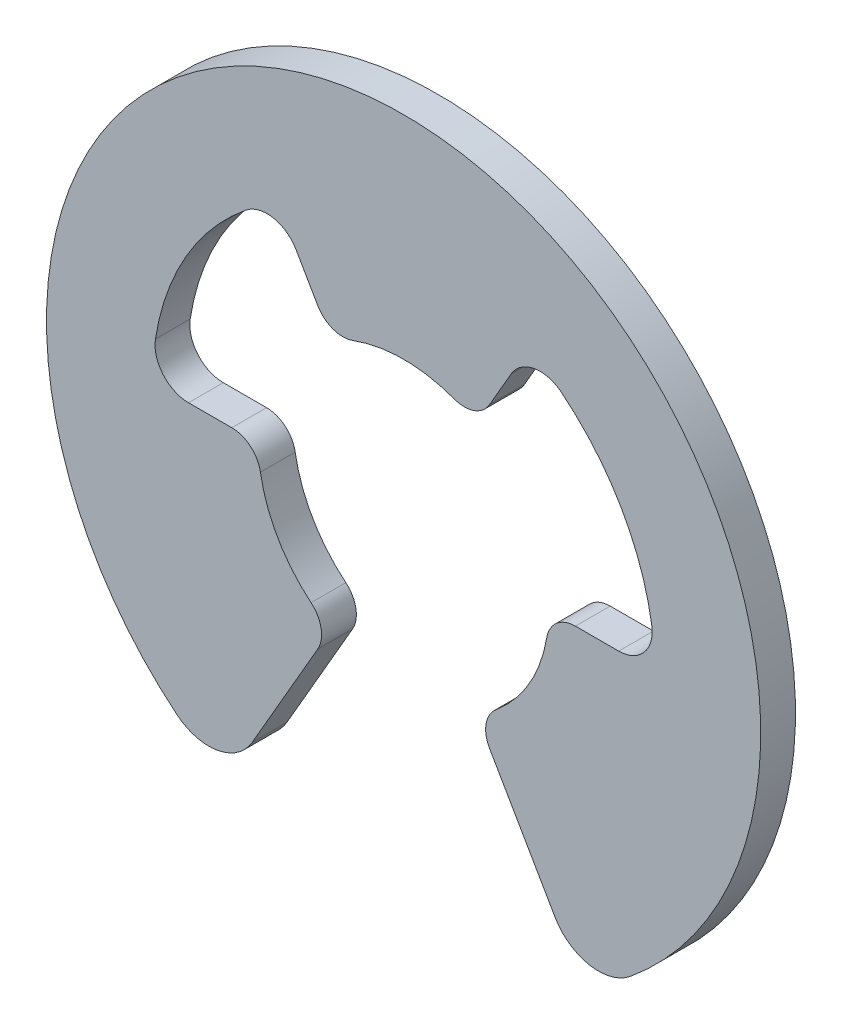
from build123d import *

# Parameters (mm, degrees)
BOSS_EXTRUDE1_DEPTH      = 0.46355
BOSS_EXTRUDE1_DEPTH_BACK = 0.46355


with BuildPart() as part:
    # Sketch1 → Boss-Extrude1 (new, two sides: drawn at the far end of the back side and taken through both)
    with BuildSketch(Plane.XY.offset(-BOSS_EXTRUDE1_DEPTH_BACK)):
        with BuildLine():
            Line((-4.037371747, -6.992932995), (-2.291593504, -3.969156379))
            ThreePointArc((-2.291593504, -3.969156379), (-2.200054149, -3.444579363), (-2.46875282, -2.984838649))
            ThreePointArc((-2.46875282, -2.984838649), (-3.354549402, -1.93675), (-3.819322507, -0.645583333))
            ThreePointArc((-3.819322507, -0.645583333), (-4.083120308, -0.183013102), (-4.583187008, 0))
            Line((-4.583187008, 0), (-5.736894957, 0))
            ThreePointArc((-5.736894957, 0), (-6.415354377, 0.312235397), (-6.619494181, 1.030653846))
            ThreePointArc((-6.619494181, 1.030653846), (-5.801720686, 3.349625), (-4.202319504, 5.217323198))
            ThreePointArc((-4.202319504, 5.217323198), (-3.478080974, 5.399742167), (-2.868447478, 4.968296771))
            Line((-2.868447478, 4.968296771), (-2.291593504, 3.969156379))
            ThreePointArc((-2.291593504, 3.969156379), (-1.883066138, 3.627592457), (-1.350569645, 3.630421998))
            ThreePointArc((-1.350569645, 3.630421998), (2.2e-08, 3.8735), (1.350569686, 3.630421983))
            ThreePointArc((1.350569686, 3.630421983), (1.883066159, 3.627592464), (2.291593504, 3.969156379))
            Line((2.291593504, 3.969156379), (2.868447478, 4.968296771))
            ThreePointArc((2.868447478, 4.968296771), (3.478080974, 5.399742167), (4.202319504, 5.217323198))
            ThreePointArc((4.202319504, 5.217323198), (5.801720686, 3.349625), (6.619494181, 1.030653846))
            ThreePointArc((6.619494181, 1.030653846), (6.415354377, 0.312235397), (5.736894957, 0))
            Line((5.736894957, 0), (4.583187008, 0))
            ThreePointArc((4.583187008, 0), (4.083120299, -0.183013109), (3.819322503, -0.645583357))
            ThreePointArc((3.819322503, -0.645583357), (3.354549396, -1.93675001), (2.46875282, -2.984838649))
            ThreePointArc((2.46875282, -2.984838649), (2.200054149, -3.444579363), (2.291593504, -3.969156379))
            Line((2.291593504, -3.969156379), (4.037371747, -6.992932995))
            ThreePointArc((4.037371747, -6.992932995), (4.958392768, -7.64131087), (6.048544388, -7.358038855))
            ThreePointArc((6.048544388, -7.358038855), (5.5e-08, 9.525), (-6.048544474, -7.358038784))
            ThreePointArc((-6.048544474, -7.358038784), (-4.958392823, -7.641310879), (-4.037371747, -6.992932995))
        make_face()
    extrude(amount=BOSS_EXTRUDE1_DEPTH + BOSS_EXTRUDE1_DEPTH_BACK)


solid = part.part
